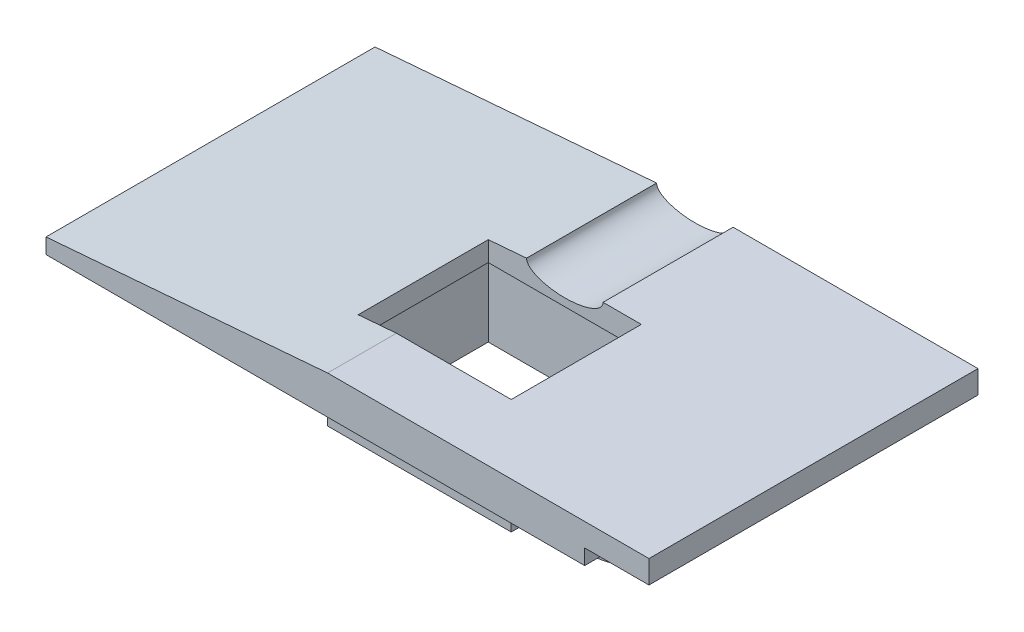
from build123d import *

# Parameters (mm, degrees)
SALIENTE_EXTRUIR1_DEPTH  = 21.5
CORTAR_EXTRUIR1_DEPTH    = 8.5
CORTAR_EXTRUIR2_DEPTH    = 3.5000001
CROQUIS5_W               = 12
CROQUIS5_H               = 10.5
SALIENTE_EXTRUIR2_DEPTH  = 4
CROQUIS6_W               = 11
CROQUIS6_H               = 9.5
CORTAR_EXTRUIR3_DEPTH    = 5
CROQUIS8_R               = 2.95
SALIENTE_EXTRUIR8_DEPTH  = 5
CROQUIS9_R               = 0.95
CORTAR_EXTRUIR4_DEPTH    = 5.5
CROQUIS12_R              = 2.9
SALIENTE_EXTRUIR14_DEPTH = 5
CROQUIS13_R              = 0.9
CORTAR_EXTRUIR5_DEPTH    = 5.5


with BuildPart() as part:
    # Croquis1 → Saliente-Extruir1 (new body)
    with BuildSketch(Plane.XY):
        Polygon((-7.838981289, 5.169230769), (13.161018711, 5.169230769), (13.161018711, 3.669230769), (8.961018711, 3.669230769), (8.961018711, 2.669230769), (-26.238981289, 2.669230769), (-26.238981289, 3.669230769), align=None)
    extrude(amount=SALIENTE_EXTRUIR1_DEPTH)

    # Croquis2 → Cortar-Extruir1 (cut)
    with BuildSketch(Plane(origin=(0, 0, 0), x_dir=(-1, 0, 0), z_dir=(0, 0, -1))):
        with BuildLine():
            Line((2.838981289, 5.169230769), (7.838981289, 5.169230769))
            add(Edge.make_bspline(
                [(5.338981289, 4.169230769), (7.838981289, 4.169230769), (7.838981289, 5.169230769)],
                knots=[4.71238898, 4.71238898, 4.71238898, 6.283185307, 6.283185307, 6.283185307], degree=2, weights=[1, 0.707106781, 1]))
            add(Edge.make_bspline(
                [(2.838981289, 5.169230769), (2.838981289, 4.169230769), (5.338981289, 4.169230769)],
                knots=[0, 0, 0, 1.570796327, 1.570796327, 1.570796327], degree=2, weights=[1, 0.707106781, 1]))
        make_face()
    extrude(amount=-CORTAR_EXTRUIR1_DEPTH, mode=Mode.SUBTRACT)

    # Croquis3 → Cortar-Extruir2 (cut, through all)
    with BuildSketch(Plane(origin=(0, 5.169230769, 0), x_dir=(1, 0, 0), z_dir=(0, 1, 0))):
        Polygon((-5.338981289, -8.5), (-10.338981289, -8.5), (-10.338981289, -17), (-0.338981289, -17), (-0.338981289, -8.5), align=None)
    extrude(amount=-CORTAR_EXTRUIR2_DEPTH, mode=Mode.SUBTRACT)

    # Croquis5 → Saliente-Extruir2 (add)
    with BuildSketch(Plane.XZ.offset(-2.669230769)):
        with Locations((-5.338981289, 12.75)):
            Rectangle(CROQUIS5_W, CROQUIS5_H)
    extrude(amount=SALIENTE_EXTRUIR2_DEPTH)

    # Croquis6 → Cortar-Extruir3 (cut)
    with BuildSketch(Plane.XZ.offset(1.330769231)):
        with Locations((-5.338981289, 12.75)):
            Rectangle(CROQUIS6_W, CROQUIS6_H)
    extrude(amount=-CORTAR_EXTRUIR3_DEPTH, mode=Mode.SUBTRACT)

    # Croquis8 → Saliente-Extruir8 (add)
    with BuildSketch(Plane.XZ.offset(-2.669230769)):
        with Locations((3.561018711, 12.75)):
            Circle(CROQUIS8_R)
    extrude(amount=SALIENTE_EXTRUIR8_DEPTH)

    # Croquis9 → Cortar-Extruir4 (cut)
    with BuildSketch(Plane.XZ.offset(2.330769231)):
        with Locations((3.561018711, 12.75)):
            Circle(CROQUIS9_R)
    extrude(amount=-CORTAR_EXTRUIR4_DEPTH, mode=Mode.SUBTRACT)

    # Croquis12 → Saliente-Extruir14 (add)
    with BuildSketch(Plane.XZ.offset(-2.669230769)):
        with Locations((-14.248981289, 12.75)):
            Circle(CROQUIS12_R)
    extrude(amount=SALIENTE_EXTRUIR14_DEPTH)

    # Croquis13 → Cortar-Extruir5 (cut)
    with BuildSketch(Plane.XZ.offset(2.330769231)):
        with Locations((-14.248981289, 12.75)):
            Circle(CROQUIS13_R)
    extrude(amount=-CORTAR_EXTRUIR5_DEPTH, mode=Mode.SUBTRACT)


solid = part.part
